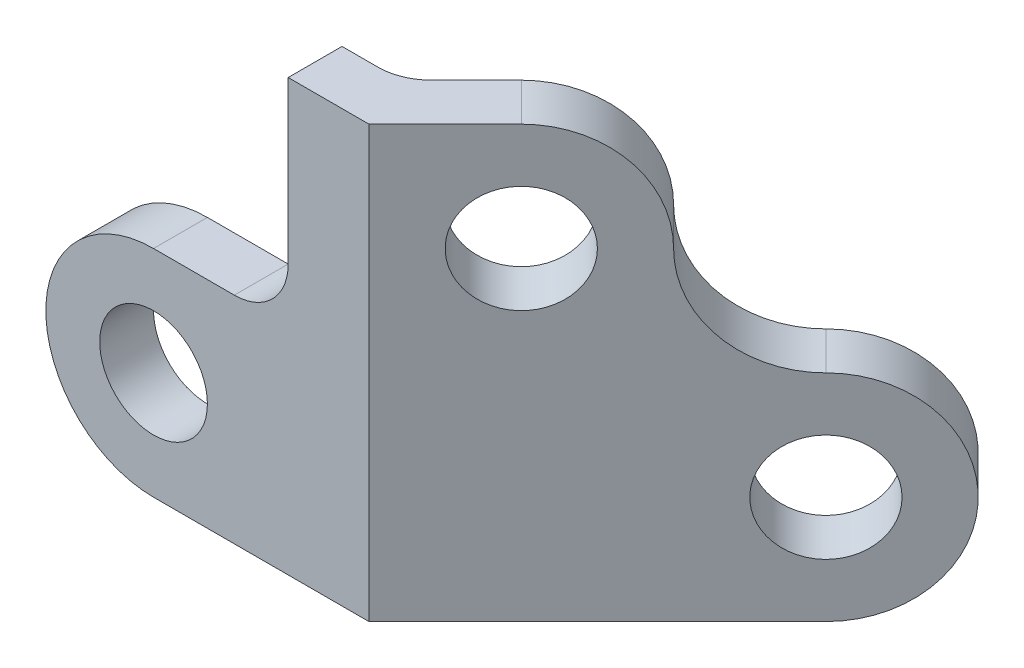
from build123d import *

# Parameters (mm, degrees)
SKETCH_1_R      = 10
EXTRUDE_1_DEPTH = 10
SKETCH_2_R      = 10
EXTRUDE_2_DEPTH = 10
FILLET_1_R      = 10


with BuildPart() as part:
    # 草圖1 → 填料-伸長1 (new body)
    with BuildSketch(Plane.XY):
        with BuildLine():
            Line((0, 80), (0, 0))
            Line((0, 0), (-40, 0))
            ThreePointArc((-40, 0), (-60, 20), (-40, 40))
            Line((-40, 40), (-25, 40))
            ThreePointArc((-25, 40), (-17.928932188, 42.928932188), (-15, 50))
            Line((-15, 50), (-15, 80))
            Line((-15, 80), (0, 80))
        make_face()
        with Locations((-40, 20)):
            Circle(SKETCH_1_R, mode=Mode.SUBTRACT)
    extrude(amount=-EXTRUDE_1_DEPTH)

    # 草圖2 → 填料-伸長2 (add)
    with BuildSketch(Plane(origin=(0, 0, 0), x_dir=(0, -1, 0), z_dir=(0.707106781, 0, 0.707106781))):
        with BuildLine():
            Line((0, 60), (0, 0))
            Line((0, 0), (-80, 0))
            Line((-80, 0), (-80, 20))
            ThreePointArc((-80, 20), (-74.142135624, 34.142135624), (-60, 40))
            ThreePointArc((-60, 40), (-45.857864376, 45.857864376), (-40, 60))
            ThreePointArc((-40, 60), (-20, 80), (0, 60))
        make_face()
        with Locations((-60, 20)):
            Circle(SKETCH_2_R, mode=Mode.SUBTRACT)
        with Locations((-20, 60)):
            Circle(SKETCH_2_R, mode=Mode.SUBTRACT)
    extrude(amount=-EXTRUDE_2_DEPTH)

    # 圓角1
    fillet_1_edges = [part.edges().sort_by_distance(p)[0] for p in [
        (-4.142135624, 40, -10),
    ]]
    fillet(fillet_1_edges, radius=FILLET_1_R)


solid = part.part
